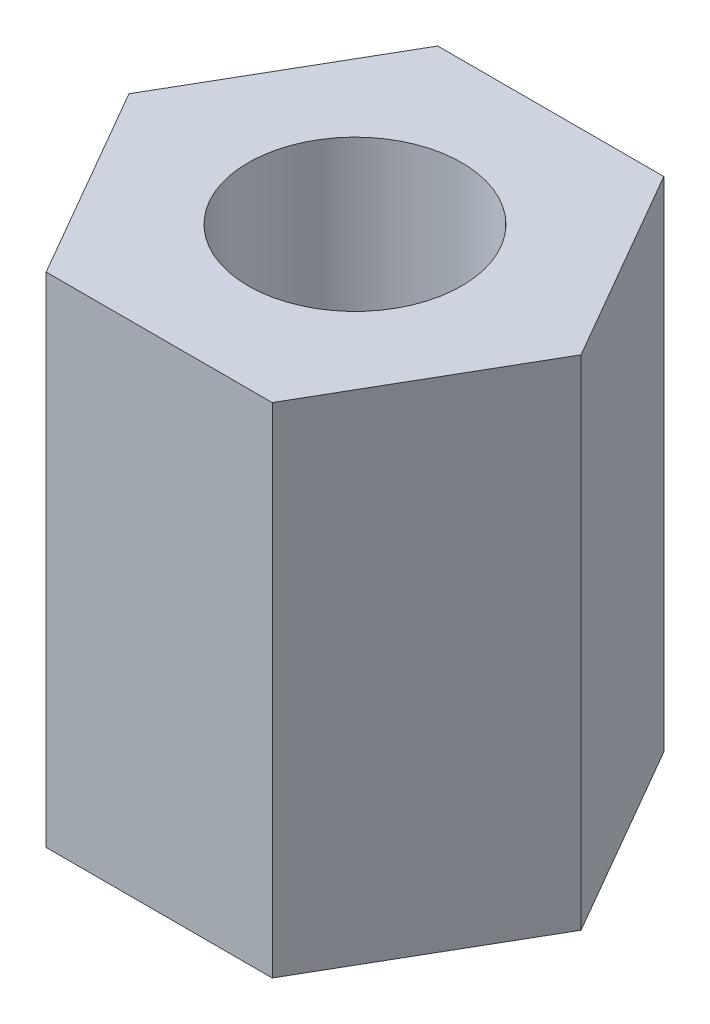
from build123d import *

# Parameters (mm, degrees)
SKETCH_1_R      = 1.5
EXTRUDE_1_DEPTH = 7


with BuildPart() as part:
    # 草图1 → 凸台-拉伸1 (new body)
    with BuildSketch(Plane(origin=(0, 0, 0), x_dir=(1, 0, 0), z_dir=(0, 1, 0))):
        Polygon((3.175426481, 0), (1.58771324, 2.75), (-1.58771324, 2.75), (-3.175426481, 0), (-1.58771324, -2.75), (1.58771324, -2.75), align=None)
        Circle(SKETCH_1_R, mode=Mode.SUBTRACT)
    extrude(amount=EXTRUDE_1_DEPTH)


solid = part.part
